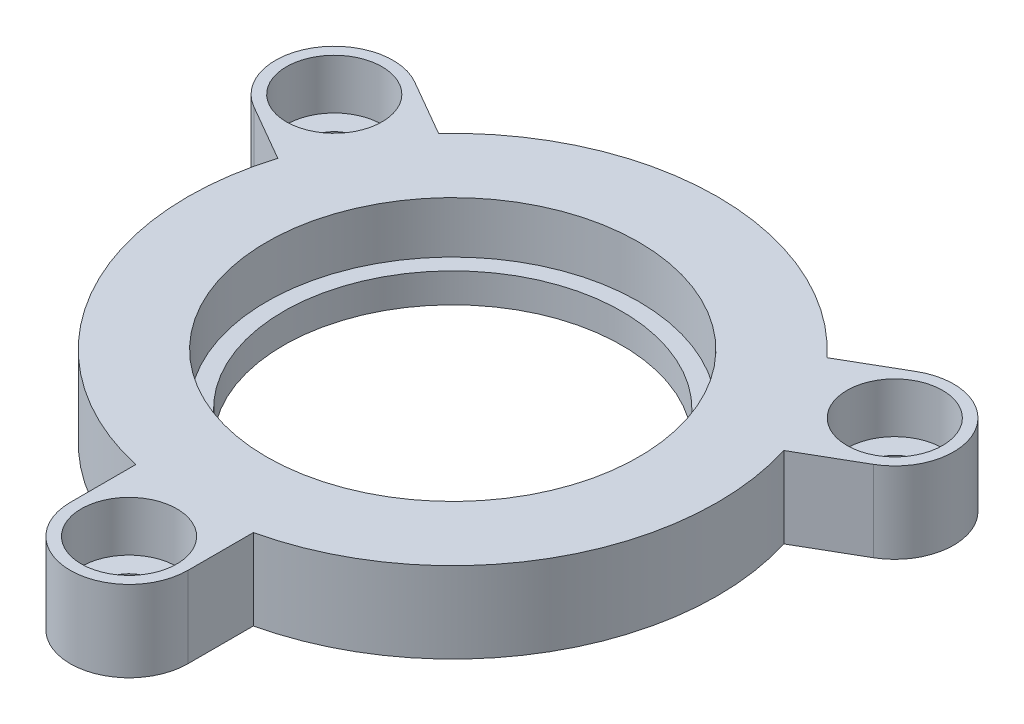
from build123d import *

# Parameters (mm, degrees)
SKETCH1_R                                           = 11.5
BOSS_EXTRUDE1_DEPTH                                 = 5.5
CUT_EXTRUDE1_START                                  = 2
SKETCH1_3_R                                         = 12.65
CUT_EXTRUDE1_DEPTH                                  = 3.5
CBORE_FOR_M3_HEX_SOCKET_HEAD_CAP_SCREW1_D           = 3.4
CBORE_FOR_M3_HEX_SOCKET_HEAD_CAP_SCREW1_DEPTH       = 45
CBORE_FOR_M3_HEX_SOCKET_HEAD_CAP_SCREW1_CBORE_D     = 6.5
CBORE_FOR_M3_HEX_SOCKET_HEAD_CAP_SCREW1_CBORE_DEPTH = 3.4
CBORE_FOR_M3_HEX_SOCKET_HEAD_CAP_SCREW1_TIP         = 1.021463052


with BuildPart() as part:
    # Sketch1 → Boss-Extrude1 (new body)
    with BuildSketch(Plane(origin=(0, 0, 0), x_dir=(1, 0, 0), z_dir=(0, 1, 0))):
        with BuildLine():
            ThreePointArc((-4, -22), (0, -26), (4, -22))
            Line((4, -22), (4, -17.549928775))
            ThreePointArc((4, -17.549928775), (15.588457268, -9), (17.198684154, 5.310862772))
            Line((17.198684154, 5.310862772), (21.052558883, 7.535898385))
            ThreePointArc((21.052558883, 7.535898385), (22.516660498, 13), (17.052558883, 14.464101615))
            Line((17.052558883, 14.464101615), (13.198684154, 12.239066003))
            ThreePointArc((13.198684154, 12.239066003), (0, 18), (-13.198684154, 12.239066003))
            Line((-13.198684154, 12.239066003), (-17.052558883, 14.464101615))
            ThreePointArc((-17.052558883, 14.464101615), (-22.516660498, 13), (-21.052558883, 7.535898385))
            Line((-21.052558883, 7.535898385), (-17.198684154, 5.310862772))
            ThreePointArc((-17.198684154, 5.310862772), (-15.588457268, -9), (-4, -17.549928775))
            Line((-4, -17.549928775), (-4, -22))
        make_face()
        Circle(SKETCH1_R, mode=Mode.SUBTRACT)
    extrude(amount=BOSS_EXTRUDE1_DEPTH)

    # Sketch1_3 → Cut-Extrude1 (cut)
    with BuildSketch(Plane(origin=(0, 0, 0), x_dir=(1, 0, 0), z_dir=(0, 1, 0)).offset(CUT_EXTRUDE1_START)):
        Circle(SKETCH1_3_R)
    extrude(amount=CUT_EXTRUDE1_DEPTH, mode=Mode.SUBTRACT)

    # CBORE for M3 Hex Socket Head Cap Screw1
    with Locations(Plane(origin=(0, 5.5, 0), x_dir=(1, 0, 0), z_dir=(0, 1, 0))):
        with Locations((-19.052558883, 11), (19.052558883, 11), (0, -22)):
            CounterBoreHole(CBORE_FOR_M3_HEX_SOCKET_HEAD_CAP_SCREW1_D / 2, CBORE_FOR_M3_HEX_SOCKET_HEAD_CAP_SCREW1_CBORE_D / 2, CBORE_FOR_M3_HEX_SOCKET_HEAD_CAP_SCREW1_CBORE_DEPTH, depth=CBORE_FOR_M3_HEX_SOCKET_HEAD_CAP_SCREW1_DEPTH)
            with Locations((0, 0, -(CBORE_FOR_M3_HEX_SOCKET_HEAD_CAP_SCREW1_DEPTH + CBORE_FOR_M3_HEX_SOCKET_HEAD_CAP_SCREW1_TIP / 2))):  # 118° drill point
                Cone(0, CBORE_FOR_M3_HEX_SOCKET_HEAD_CAP_SCREW1_D / 2, CBORE_FOR_M3_HEX_SOCKET_HEAD_CAP_SCREW1_TIP, mode=Mode.SUBTRACT)


solid = part.part
